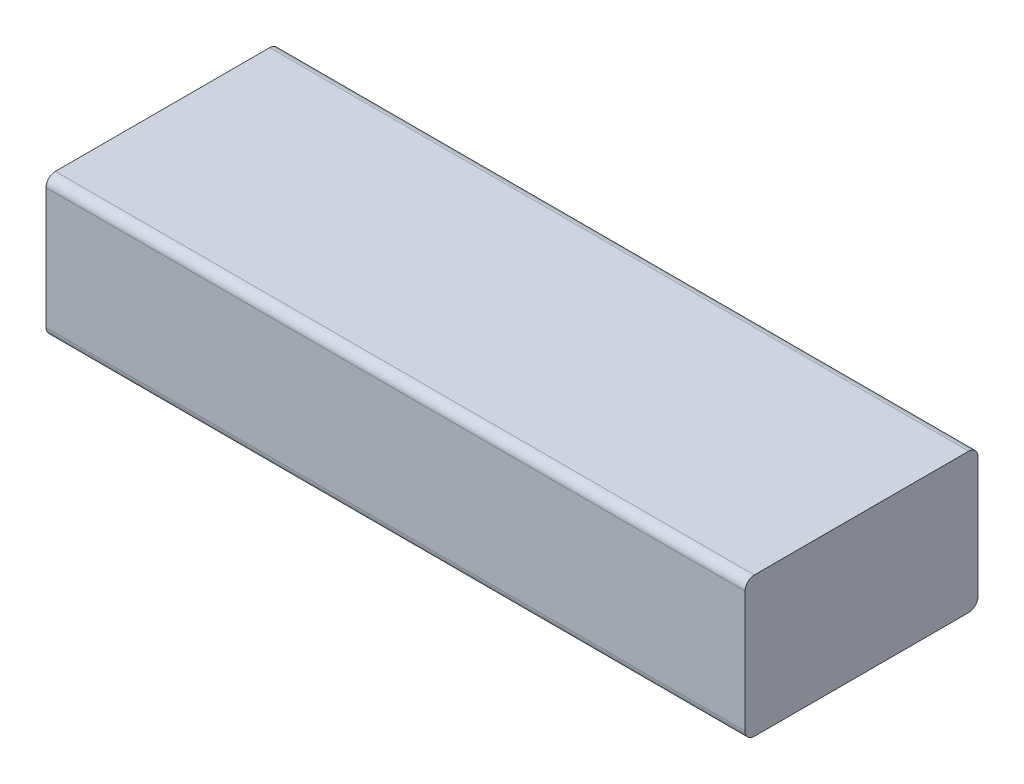
from build123d import *

# Parameters (mm, degrees)
SKETCH1_W           = 75
SKETCH1_H           = 25
BOSS_EXTRUDE1_DEPTH = 15
FILLET1_R           = 1


with BuildPart() as part:
    # Sketch1 → Boss-Extrude1 (new body)
    with BuildSketch(Plane(origin=(0, 0, 0), x_dir=(1, 0, 0), z_dir=(0, 1, 0))):
        with Locations((13.571428571, 4.553571429)):
            Rectangle(SKETCH1_W, SKETCH1_H)
    extrude(amount=BOSS_EXTRUDE1_DEPTH)

    # Fillet1
    fillet1_edges = [part.edges().sort_by_distance(p)[0] for p in [
        (13.571428571, 15, -17.053571429),
        (13.571428571, 0, -17.053571429),
        (13.571428571, 0, 7.946428571),
        (13.571428571, 15, 7.946428571),
    ]]
    fillet(fillet1_edges, radius=FILLET1_R)


solid = part.part
